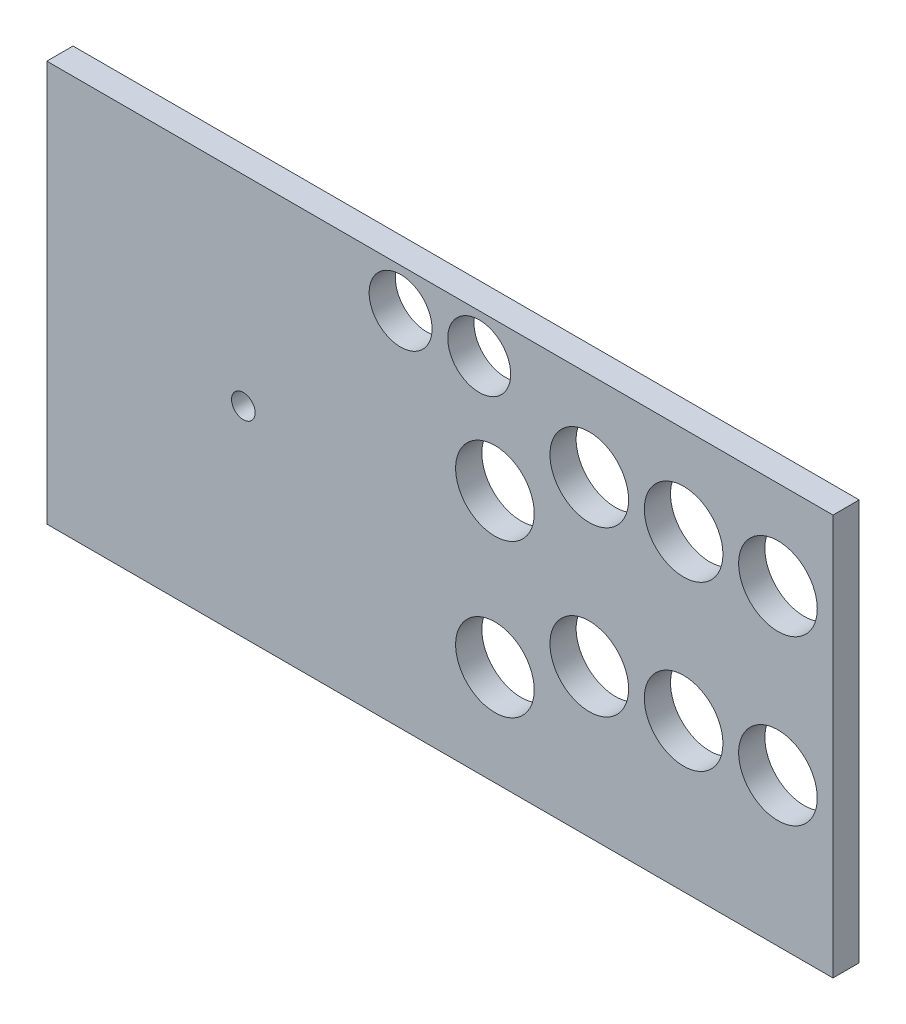
from build123d import *

# Parameters (mm, degrees)
ESQUISSE1_W              = 300
ESQUISSE1_H              = 153
BOSS_EXTRU_1_DEPTH       = 10
ESQUISSE7_R              = 15
ENL_V_MAT_EXTRU_5_DEPTH  = 11
ESQUISSE8_R              = 15
ENL_V_MAT_EXTRU_6_DEPTH  = 11
ESQUISSE9_R              = 15
ENL_V_MAT_EXTRU_7_DEPTH  = 11
ESQUISSE10_R             = 15
ENL_V_MAT_EXTRU_8_DEPTH  = 11
ESQUISSE11_R             = 15
ENL_V_MAT_EXTRU_9_DEPTH  = 11
ESQUISSE12_R             = 15
ENL_V_MAT_EXTRU_10_DEPTH = 11
ESQUISSE13_R             = 15
ENL_V_MAT_EXTRU_11_DEPTH = 11
ESQUISSE14_R             = 15
ENL_V_MAT_EXTRU_12_DEPTH = 11
ESQUISSE16_R             = 12
ENL_V_MAT_EXTRU_14_DEPTH = 11
ESQUISSE17_R             = 12
ENL_V_MAT_EXTRU_15_DEPTH = 11
ESQUISSE2_R              = 4.5
ENL_V_MAT_EXTRU_16_DEPTH = 11


with BuildPart() as part:
    # Esquisse1 → Boss.-Extru.1 (new body)
    with BuildSketch(Plane.XY):
        with Locations((150, 76.5)):
            Rectangle(ESQUISSE1_W, ESQUISSE1_H)
    extrude(amount=BOSS_EXTRU_1_DEPTH)

    # Esquisse7 → Enlèv. mat.-Extru.5 (cut, through all)
    with BuildSketch(Plane.XY.offset(10)):
        with Locations((171, 96.5)):
            Circle(ESQUISSE7_R)
    extrude(amount=-ENL_V_MAT_EXTRU_5_DEPTH, mode=Mode.SUBTRACT)

    # Esquisse8 → Enlèv. mat.-Extru.6 (cut, through all)
    with BuildSketch(Plane.XY.offset(10)):
        with Locations((207, 119)):
            Circle(ESQUISSE8_R)
    extrude(amount=-ENL_V_MAT_EXTRU_6_DEPTH, mode=Mode.SUBTRACT)

    # Esquisse9 → Enlèv. mat.-Extru.7 (cut, through all)
    with BuildSketch(Plane.XY.offset(10)):
        with Locations((243, 119)):
            Circle(ESQUISSE9_R)
    extrude(amount=-ENL_V_MAT_EXTRU_7_DEPTH, mode=Mode.SUBTRACT)

    # Esquisse10 → Enlèv. mat.-Extru.8 (cut, through all)
    with BuildSketch(Plane.XY.offset(10)):
        with Locations((279, 119)):
            Circle(ESQUISSE10_R)
    extrude(amount=-ENL_V_MAT_EXTRU_8_DEPTH, mode=Mode.SUBTRACT)

    # Esquisse11 → Enlèv. mat.-Extru.9 (cut, through all)
    with BuildSketch(Plane.XY.offset(10)):
        with Locations((171, 38.2)):
            Circle(ESQUISSE11_R)
    extrude(amount=-ENL_V_MAT_EXTRU_9_DEPTH, mode=Mode.SUBTRACT)

    # Esquisse12 → Enlèv. mat.-Extru.10 (cut, through all)
    with BuildSketch(Plane.XY.offset(10)):
        with Locations((207, 56.5)):
            Circle(ESQUISSE12_R)
    extrude(amount=-ENL_V_MAT_EXTRU_10_DEPTH, mode=Mode.SUBTRACT)

    # Esquisse13 → Enlèv. mat.-Extru.11 (cut, through all)
    with BuildSketch(Plane.XY.offset(10)):
        with Locations((243, 56.5)):
            Circle(ESQUISSE13_R)
    extrude(amount=-ENL_V_MAT_EXTRU_11_DEPTH, mode=Mode.SUBTRACT)

    # Esquisse14 → Enlèv. mat.-Extru.12 (cut, through all)
    with BuildSketch(Plane.XY.offset(10)):
        with Locations((279, 56.5)):
            Circle(ESQUISSE14_R)
    extrude(amount=-ENL_V_MAT_EXTRU_12_DEPTH, mode=Mode.SUBTRACT)

    # Esquisse16 → Enlèv. mat.-Extru.14 (cut, through all)
    with BuildSketch(Plane.XY.offset(10)):
        with Locations((165, 138)):
            Circle(ESQUISSE16_R)
    extrude(amount=-ENL_V_MAT_EXTRU_14_DEPTH, mode=Mode.SUBTRACT)

    # Esquisse17 → Enlèv. mat.-Extru.15 (cut, through all)
    with BuildSketch(Plane.XY.offset(10)):
        with Locations((135, 138)):
            Circle(ESQUISSE17_R)
    extrude(amount=-ENL_V_MAT_EXTRU_15_DEPTH, mode=Mode.SUBTRACT)

    # Esquisse2 → Enlèv. mat.-Extru.16 (cut, through all)
    with BuildSketch(Plane.XY.offset(10)):
        with Locations((75, 76.5)):
            Circle(ESQUISSE2_R)
    extrude(amount=-ENL_V_MAT_EXTRU_16_DEPTH, mode=Mode.SUBTRACT)


solid = part.part
